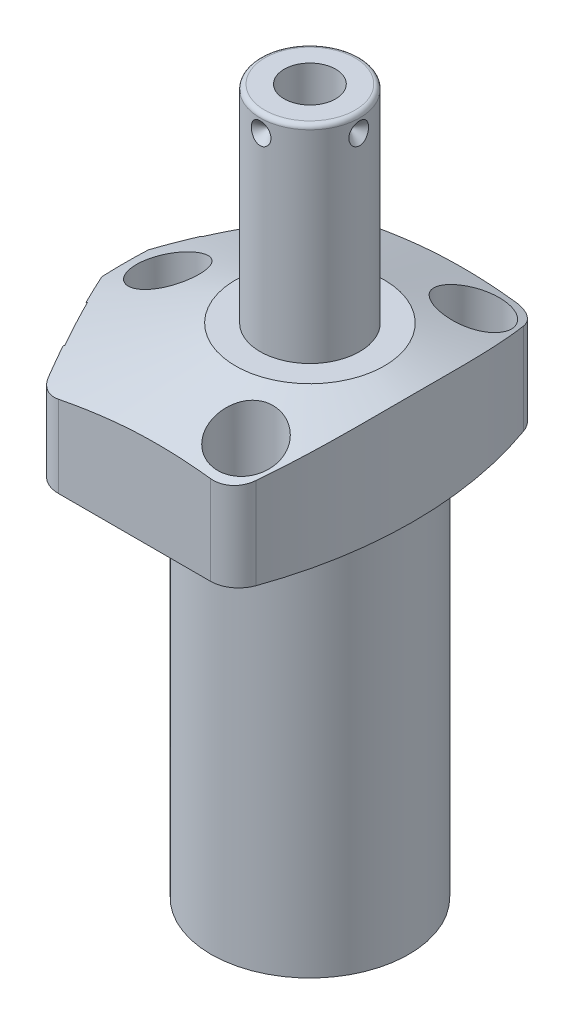
from build123d import *

# Parameters (mm, degrees)
CUT_EXTRUDE1_REACH = 28.975
CUT_EXTRUDE2_REACH = 28.975
S2D0002_OUTSIDE_W  = 122.011
S2D0002_OUTSIDE_H  = 101.742
CUT_EXTRUDE3_DEPTH = 38.0873
FILLET1_R          = 6.35
FILLET2_R          = 6.35
FILLET3_R          = 6.35
SKETCH17_R         = 10.4775
CUT_EXTRUDE4_DEPTH = 0.254
SKETCH18_R         = 5.5626
CUT_EXTRUDE5_DEPTH = 2.667
HOLE1_D            = 8.7376
HOLE1_DEPTH        = 26.9748
HOLE1_CBORE_D      = 13.9954
HOLE1_CBORE_DEPTH  = 16.6624
CIRPATTERN1_COUNT  = 4


with BuildPart() as part:
    # Sketch1 → Revolve1 (revolve)
    with BuildSketch(Plane(origin=(0, 0, 0), x_dir=(0, -1, 0), z_dir=(0, 0, 1)), mode=Mode.PRIVATE) as revolve1_sk:
        Polygon((0, 44.45), (-26.9748, 44.45), (-26.9748, 0), (84.1502, 0), (84.1502, 22.098), (0, 22.098), align=None)
    revolve(revolve1_sk.sketch.rotate(Axis((0, 32.53105, 0), (0, -1, 0)), 90), axis=Axis((0, 32.53105, 0), (0, -1, 0)))  # turned: the seam where the file's is

    # Sketch2 → Cut-Extrude1 (cut, up to next)
    with BuildSketch(Plane(origin=(0, 0, 0), x_dir=(0, 0, -1), z_dir=(0, -1, 0)), mode=Mode.PRIVATE) as cut_extrude1_sk1:
        with BuildLine():
            Line((34.1122, -28.498426468), (34.1122, 28.498426468))
            ThreePointArc((34.1122, 28.498426468), (44.45, 0), (34.1122, -28.498426468))
        make_face()
    cut_extrude1_tool1 = extrude(cut_extrude1_sk1.sketch, amount=-CUT_EXTRUDE1_REACH, mode=Mode.PRIVATE) & part.part
    add(cut_extrude1_tool1.solids().sort_by_distance((0, 0, -38.291522))[0], mode=Mode.SUBTRACT)
    # Sketch2 → Cut-Extrude1 (cut, up to next)
    with BuildSketch(Plane(origin=(0, 0, 0), x_dir=(0, 0, -1), z_dir=(0, -1, 0)), mode=Mode.PRIVATE) as cut_extrude1_sk2:
        with BuildLine():
            Line((-34.1122, 28.498426468), (-34.1122, -28.498426468))
            ThreePointArc((-34.1122, -28.498426468), (-44.45, 0), (-34.1122, 28.498426468))
        make_face()
    cut_extrude1_tool2 = extrude(cut_extrude1_sk2.sketch, amount=-CUT_EXTRUDE1_REACH, mode=Mode.PRIVATE) & part.part
    add(cut_extrude1_tool2.solids().sort_by_distance((0, 0, 38.291522))[0], mode=Mode.SUBTRACT)

    # Sketch3 → Cut-Extrude2 (cut, up to next)
    with BuildSketch(Plane(origin=(0, 0, 0), x_dir=(-1, 0, 0), z_dir=(0, -1, 0)), mode=Mode.PRIVATE) as cut_extrude2_sk1:
        with BuildLine():
            Line((25.904926114, 34.1122), (44.042704589, 0))
            Line((44.042704589, 0), (25.904926114, -34.1122))
            Line((25.904926114, -34.1122), (28.498426468, -34.1122))
            ThreePointArc((28.498426468, -34.1122), (44.45, 0), (28.498426468, 34.1122))
            Line((28.498426468, 34.1122), (25.904926114, 34.1122))
        make_face()
    cut_extrude2_tool1 = extrude(cut_extrude2_sk1.sketch, amount=-CUT_EXTRUDE2_REACH, mode=Mode.PRIVATE) & part.part
    add(cut_extrude2_tool1.solids().sort_by_distance((-27.201676, 0, -33.4052))[0], mode=Mode.SUBTRACT)

    # S2D0002 outside → Cut-Extrude3 (cut)
    with BuildSketch(Plane(origin=(0, 0, 0), x_dir=(-1, 0, 0), z_dir=(0, -1, 0))):
        with Locations((-0.2035, 0)):
            Rectangle(S2D0002_OUTSIDE_W, S2D0002_OUTSIDE_H)
        with BuildLine():
            Line((41.275, 85.424995881), (41.275, -85.424995881))
            ThreePointArc((41.275, -85.424995881), (-23.0124, 0), (41.275, 85.424995881))
        make_face(mode=Mode.SUBTRACT)
    extrude(amount=-CUT_EXTRUDE3_DEPTH, mode=Mode.SUBTRACT)

    # Fillet1
    fillet1_edges = [part.edges().sort_by_distance(p)[0] for p in [
        (16.207270797, 13.4874, 34.1122),
        (16.207270797, 13.4874, -34.1122),
    ]]
    fillet(fillet1_edges, radius=FILLET1_R)

    # Fillet2
    fillet2_edges = [part.edges().sort_by_distance(p)[0] for p in [
        (-25.904926114, 13.4874, 34.1122),
    ]]
    fillet(fillet2_edges, radius=FILLET2_R)

    # Fillet3
    fillet3_edges = [part.edges().sort_by_distance(p)[0] for p in [
        (-25.904926114, 13.4874, -34.1122),
    ]]
    fillet(fillet3_edges, radius=FILLET3_R)

    # Sketch5 → Cut-Revolve1 (revolve, cut)
    with BuildSketch(Plane.XY, mode=Mode.PRIVATE) as cut_revolve1_sk:
        Polygon((-16.637, 26.9748), (-47.625, 15.696090381), (-47.625, 26.9748), align=None)
    revolve(cut_revolve1_sk.sketch.rotate(Axis((0, 7.66490951, 0), (0, 1, 0)), 90), axis=Axis((0, 7.66490951, 0), (0, 1, 0)), mode=Mode.SUBTRACT)  # turned: the seam where the file's is

    # Sketch6 → Cut-Revolve2 (revolve, cut)
    with BuildSketch(Plane(origin=(-34.111267534, 10.287, -18.137282674), x_dir=(0.469471563, 0, -0.882947593), z_dir=(0, 1, 0))):
        Polygon((0, 0), (6.1849, 0), (5.642306865, -2.5527), (4.9784, -3.216606865), (4.9784, -15.748), (0, -15.748), align=None)
    revolve(axis=Axis((-19.511375907, 10.287, -10.374382594), (-0.882947593, 0, -0.469471563)), mode=Mode.SUBTRACT)

    # Sketch7 → Cut-Revolve3 (revolve, cut)
    with BuildSketch(Plane(origin=(-34.111267534, 10.287, 18.137282674), x_dir=(-0.469471563, 0, -0.882947593), z_dir=(0, 1, 0))):
        Polygon((0, 0), (6.1849, 0), (5.642306865, -2.5527), (4.9784, -3.216606865), (4.9784, -15.748), (0, -15.748), align=None)
    revolve(axis=Axis((-19.511375907, 10.287, 10.374382594), (-0.882947593, 0, 0.469471563)), mode=Mode.SUBTRACT)

    # Sketch8 → Cut-Revolve4 (revolve, cut)
    with BuildSketch(Plane(origin=(-13.4874, 2.667, -26.5938), x_dir=(-1, 0, 0), z_dir=(0, 0, 1)), mode=Mode.PRIVATE) as cut_revolve4_sk:
        Polygon((0, 0), (4.5466, 0), (4.106586662, -2.0701), (3.4544, -2.722286662), (3.4544, -12.573), (0, -12.573), align=None)
    revolve(cut_revolve4_sk.sketch.rotate(Axis((-13.4874, 15.86865, -26.5938), (0, -1, 0)), 270), axis=Axis((-13.4874, 15.86865, -26.5938), (0, -1, 0)), mode=Mode.SUBTRACT)  # turned: the seam where the file's is

    # Sketch9 → Cut-Revolve5 (revolve, cut)
    with BuildSketch(Plane(origin=(-13.4874, 2.667, 26.5938), x_dir=(-1, 0, 0), z_dir=(0, 0, 1)), mode=Mode.PRIVATE) as cut_revolve5_sk:
        Polygon((0, 0), (4.5466, 0), (4.106586662, -2.0701), (3.4544, -2.722286662), (3.4544, -12.573), (0, -12.573), align=None)
    revolve(cut_revolve5_sk.sketch.rotate(Axis((-13.4874, 15.86865, 26.5938), (0, -1, 0)), 270), axis=Axis((-13.4874, 15.86865, 26.5938), (0, -1, 0)), mode=Mode.SUBTRACT)  # turned: the seam where the file's is

    # Sketch17 → Cut-Extrude4 (cut)
    with BuildSketch(Plane(origin=(-34.335536223, 0, 18.256528451), x_dir=(0.469471563, 0, 0.882947593), z_dir=(-0.882947593, 0, 0.469471563))):
        with Locations((0, 10.287)):
            Circle(SKETCH17_R)
    cut_extrude4 = extrude(amount=-CUT_EXTRUDE4_DEPTH, mode=Mode.SUBTRACT)

    # Sketch18 → Cut-Extrude5 (cut)
    with BuildSketch(Plane.XZ):
        with Locations(Location((-13.4874, 26.5938, 0), (0, 0, 270))):  # turned: the seam where the file's is
            Circle(SKETCH18_R)
    cut_extrude5 = extrude(amount=-CUT_EXTRUDE5_DEPTH, mode=Mode.SUBTRACT)

    # Mirror1: Cut-Extrude4, Cut-Extrude5 across plane
    add(cut_extrude4.mirror(Plane.XY), mode=Mode.SUBTRACT)
    add(cut_extrude5.mirror(Plane.XY), mode=Mode.SUBTRACT)

    # Sketch10 → Revolve2 (revolve)
    with BuildSketch(Plane(origin=(0, 0, 0), x_dir=(0, 0, -1), z_dir=(1, 0, 0)), mode=Mode.PRIVATE) as revolve2_sk:
        with BuildLine():
            Line((0, 26.9748), (-11.1125, 26.9748))
            Line((-11.1125, 26.9748), (-11.1125, 72.1868))
            ThreePointArc((-11.1125, 72.1868), (-10.81492049, 72.90522049), (-10.0965, 73.2028))
            Line((-10.0965, 73.2028), (0, 73.2028))
            Line((0, 73.2028), (0, 26.9748))
        make_face()
    revolve(revolve2_sk.sketch.rotate(Axis((0, 14.351681477, 0), (0, 1, 0)), 180), axis=Axis((0, 14.351681477, 0), (0, 1, 0)))  # turned: the seam where the file's is

    # S2D0001 → Cut-Revolve6 (revolve, cut)
    with BuildSketch(Plane(origin=(5.7531, 64.8462, 0), x_dir=(1, 0, 0), z_dir=(0, 0, 1)), mode=Mode.PRIVATE) as cut_revolve6_sk:
        Polygon((0, 8.3566), (0, -8.6614), (-5.7531, -12.118211227), (-5.7531, 8.3566), align=None)
    revolve(cut_revolve6_sk.sketch.rotate(Axis((0, 37.109882775, 0), (0, 1, 0)), 90), axis=Axis((0, 37.109882775, 0), (0, 1, 0)), mode=Mode.SUBTRACT)  # turned: the seam where the file's is

    # Sketch14 → Revolve3 (revolve)
    with BuildSketch(Plane(origin=(-13.4874, 0, 26.5938), x_dir=(0, 0, -1), z_dir=(1, 0, 0))):
        with BuildLine():
            Line((5.461, 2.667), (5.461, 0.9398))
            Line((5.461, 0.9398), (5.301559456, 0.9398))
            ThreePointArc((5.301559456, 0.9398), (4.572, -0.4572), (3.842440544, 0.9398))
            Line((3.842440544, 0.9398), (3.175, 0.9398))
            ThreePointArc((3.175, 0.9398), (2.815789755, 0.791010245), (2.667, 0.4318))
            Line((2.667, 0.4318), (2.667, 0.127))
            Line((2.667, 0.127), (1.5875, 0.127))
            Line((1.5875, 0.127), (1.5875, 10.6172))
            Line((1.5875, 10.6172), (3.2512, 10.6172))
            Line((3.2512, 10.6172), (3.2512, 2.667))
            Line((3.2512, 2.667), (5.461, 2.667))
        make_face()
    revolve3 = revolve(axis=Axis((-13.4874, -1.01092, 26.5938), (0, 1, 0)))

    # Sketch15 → Cut-Revolve7 (revolve, cut)
    with BuildSketch(Plane(origin=(11.1125, 60.8838, 0), x_dir=(0, 1, 0), z_dir=(0, 0, -1)), mode=Mode.PRIVATE) as cut_revolve7_sk:
        Polygon((8.3566, 0), (10.7696, 0), (8.3566, -2.413), align=None)
    cut_revolve7 = revolve(cut_revolve7_sk.sketch.rotate(Axis((6.003069898, 69.2404, 0), (1, 0, 0)), 270), axis=Axis((6.003069898, 69.2404, 0), (1, 0, 0)), mode=Mode.SUBTRACT)  # turned: the seam where the file's is

    # Hole1
    with Locations(Plane(origin=(0, 26.9748, 0), x_dir=(-1, 0, 0), z_dir=(0, 1, 0))):
        with Locations((-11.1252, -25.4), (31.75, 0), (-11.1252, 25.4)):
            CounterBoreHole(HOLE1_D / 2, HOLE1_CBORE_D / 2, HOLE1_CBORE_DEPTH, depth=HOLE1_DEPTH)

    # Mirror2: Revolve3 across plane
    add(revolve3.mirror(Plane.XY))

    # CirPattern1: Cut-Revolve7 ×4 about axis
    cirpattern1_axis = Axis((0, 14.351681477, 0), (0, -1, 0))
    for i in range(1, CIRPATTERN1_COUNT):
        add(cut_revolve7.rotate(cirpattern1_axis, i * 360 / CIRPATTERN1_COUNT), mode=Mode.SUBTRACT)


solid = part.part
